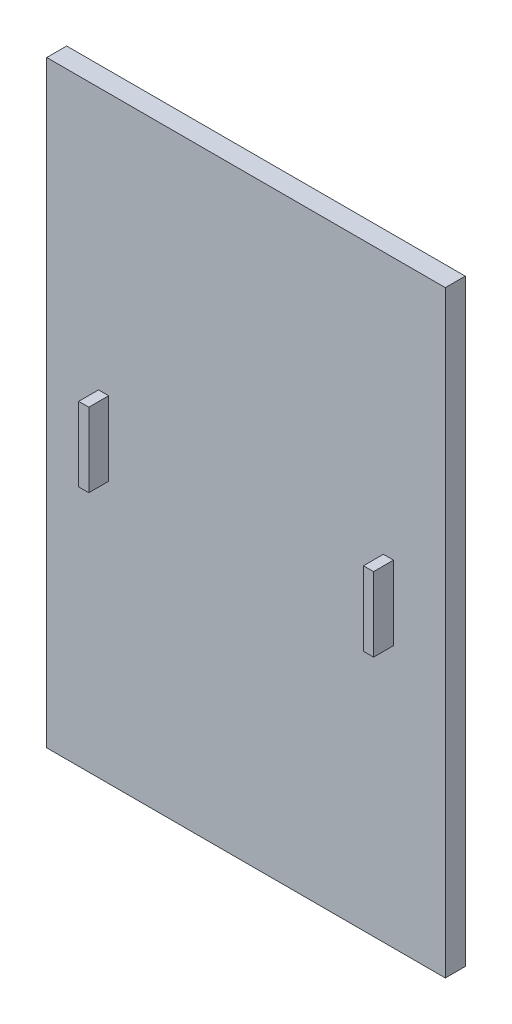
from build123d import *

# Parameters (mm, degrees)
SKETCH1_W           = 100
SKETCH1_H           = 150
BOSS_EXTRUDE1_DEPTH = 5
SKETCH2_W           = 2.543215169
SKETCH2_H           = 18.583792384
BOSS_EXTRUDE2_DEPTH = 5


with BuildPart() as part:
    # Sketch1 → Boss-Extrude1 (new body)
    with BuildSketch(Plane.XY):
        Rectangle(SKETCH1_W, SKETCH1_H)
    extrude(amount=BOSS_EXTRUDE1_DEPTH)

    # Sketch2 → Boss-Extrude2 (add)
    with BuildSketch(Plane.XY.offset(5)):
        with Locations((-35.723415387, 0)):
            Rectangle(SKETCH2_W, SKETCH2_H)
    boss_extrude2 = extrude(amount=BOSS_EXTRUDE2_DEPTH)

    # Mirror1: Boss-Extrude2 across plane
    add(boss_extrude2.mirror(Plane(origin=(0, 0, 0), x_dir=(0, 0, 1), z_dir=(1, 0, 0))))


solid = part.part
